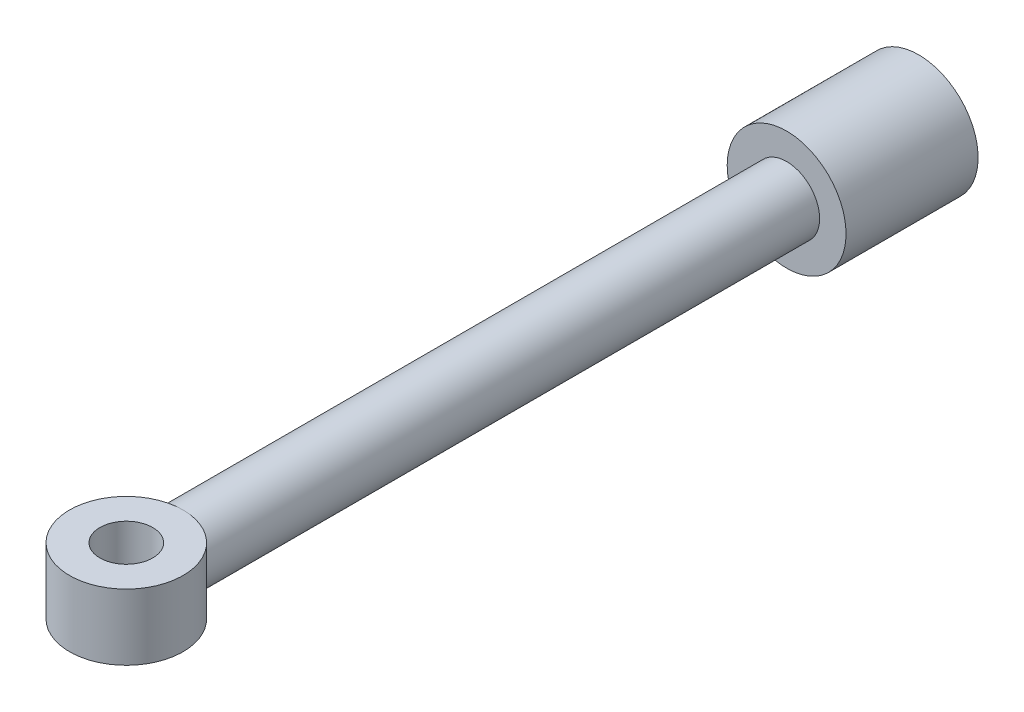
from build123d import *

# Parameters (mm, degrees)
SKETCH3_R           = 43
SKETCH3_R_2         = 20
BOSS_EXTRUDE1_DEPTH = 25


with BuildPart() as part:
    # Sketch1 → Revolve1 (revolve)
    with BuildSketch(Plane(origin=(0, 0, 0), x_dir=(1, 0, 0), z_dir=(0, 1, 0))):
        Polygon((0, -75), (45, -75), (45, -175), (25, -175), (25, -640.014288631), (0, -640.014288631), align=None)
    revolve(axis=Axis((0, 0, 75), (0, 0, 1)))

    # Sketch3 → Boss-Extrude1 (add, symmetric)
    with BuildSketch(Plane(origin=(0, 0, 0), x_dir=(1, 0, 0), z_dir=(0, 1, 0))):
        with Locations((0, -675)):
            Circle(SKETCH3_R)
        with Locations((0, -675)):
            Circle(SKETCH3_R_2, mode=Mode.SUBTRACT)
    extrude(amount=BOSS_EXTRUDE1_DEPTH, both=True)


solid = part.part
